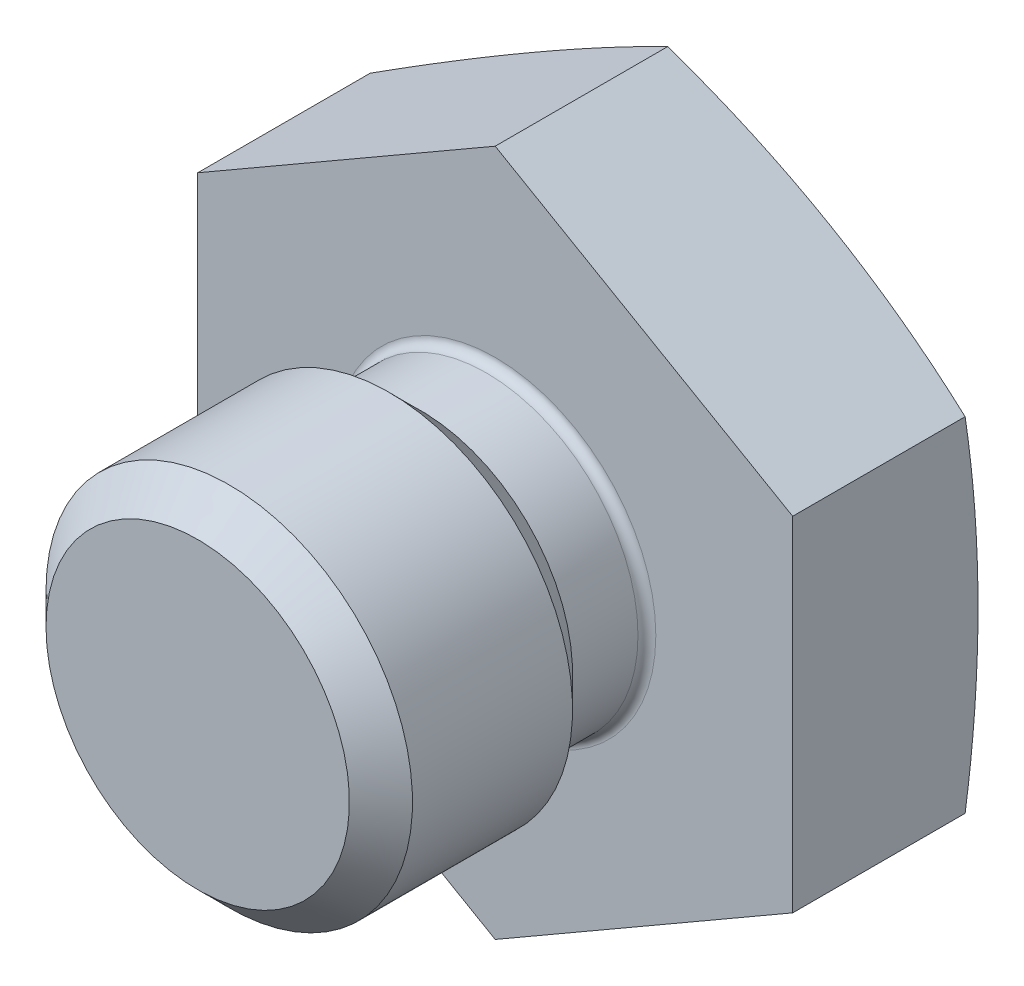
from build123d import *

# Parameters (mm, degrees)
SKETCH2_OUTSIDE_W  = 78.56
SKETCH2_OUTSIDE_H  = 78.56
CUT_EXTRUDE1_DEPTH = 10.525
FILLET1_R          = 0.381


with BuildPart() as part:
    # Sketch1 → Revolve1 (revolve)
    with BuildSketch(Plane(origin=(0, 0, 0), x_dir=(0, 0, -1), z_dir=(1, 0, 0)), mode=Mode.PRIVATE) as revolve1_sk:
        with BuildLine():
            Line((0, 29.614428494), (0, 6.477))
            Line((0, 6.477), (-3.175, 6.477))
            Line((-3.175, 6.477), (-4.5212, 7.8232))
            Line((-4.5212, 7.8232), (-11.3538, 7.8232))
            Line((-11.3538, 7.8232), (-12.7, 6.477))
            Line((-12.7, 6.477), (-12.7, 0))
            Line((-12.7, 0), (9.525, 0))
            ThreePointArc((9.525, 0), (7.085159222, 15.554259867), (0, 29.614428494))
        make_face()
    revolve(revolve1_sk.sketch.rotate(Axis((0, 0, 0), (0, 0, 1)), 90), axis=Axis((0, 0, 0), (0, 0, 1)))  # turned: the seam where the file's is

    # Sketch2 outside → Cut-Extrude1 (cut, through all)
    with BuildSketch(Plane.XY):
        Rectangle(SKETCH2_OUTSIDE_W, SKETCH2_OUTSIDE_H)
        Polygon((0, 14.664696837), (-12.7, 7.332348419), (-12.7, -7.332348419), (0, -14.664696837), (12.7, -7.332348419), (12.7, 7.332348419), align=None, mode=Mode.SUBTRACT)
    extrude(amount=-CUT_EXTRUDE1_DEPTH, mode=Mode.SUBTRACT)

    # Fillet1
    fillet1_edges = [part.edges().sort_by_distance(p)[0] for p in [
        (6.477, 0, 0),
    ]]
    fillet(fillet1_edges, radius=FILLET1_R)


solid = part.part
